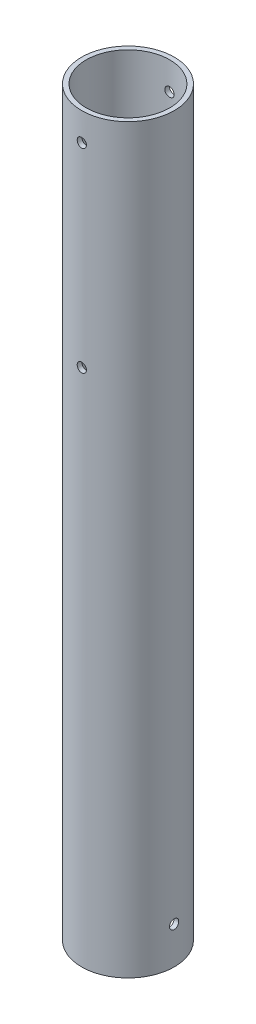
from build123d import *

# Parameters (mm, degrees)
SKETCH1_R           = 31.75
SKETCH1_R_2         = 28.575
BOSS_EXTRUDE1_DEPTH = 508
SKETCH3_R           = 3.175
CUT_EXTRUDE1_DEPTH  = 508
SKETCH7_R           = 3.175
CUT_EXTRUDE2_DEPTH  = 64.5000001


with BuildPart() as part:
    # Sketch1 → Boss-Extrude1 (new body)
    with BuildSketch(Plane(origin=(0, 0, 0), x_dir=(1, 0, 0), z_dir=(0, 1, 0))):
        Circle(SKETCH1_R)
        Circle(SKETCH1_R_2, mode=Mode.SUBTRACT)
    extrude(amount=-BOSS_EXTRUDE1_DEPTH)

    # Sketch3 → Cut-Extrude1 (cut)
    with BuildSketch(Plane.XY.offset(31.75)):
        with Locations((0, -19.05)):
            Circle(SKETCH3_R)
        with Locations((0, -152.4)):
            Circle(SKETCH3_R)
    extrude(amount=-CUT_EXTRUDE1_DEPTH, mode=Mode.SUBTRACT)

    # Sketch7 → Cut-Extrude2 (cut, through all)
    with BuildSketch(Plane(origin=(31.75, 0, 0), x_dir=(0, 0, -1), z_dir=(1, 0, 0))):
        with Locations((0, -482.6)):
            Circle(SKETCH7_R)
    extrude(amount=-CUT_EXTRUDE2_DEPTH, mode=Mode.SUBTRACT)


solid = part.part
